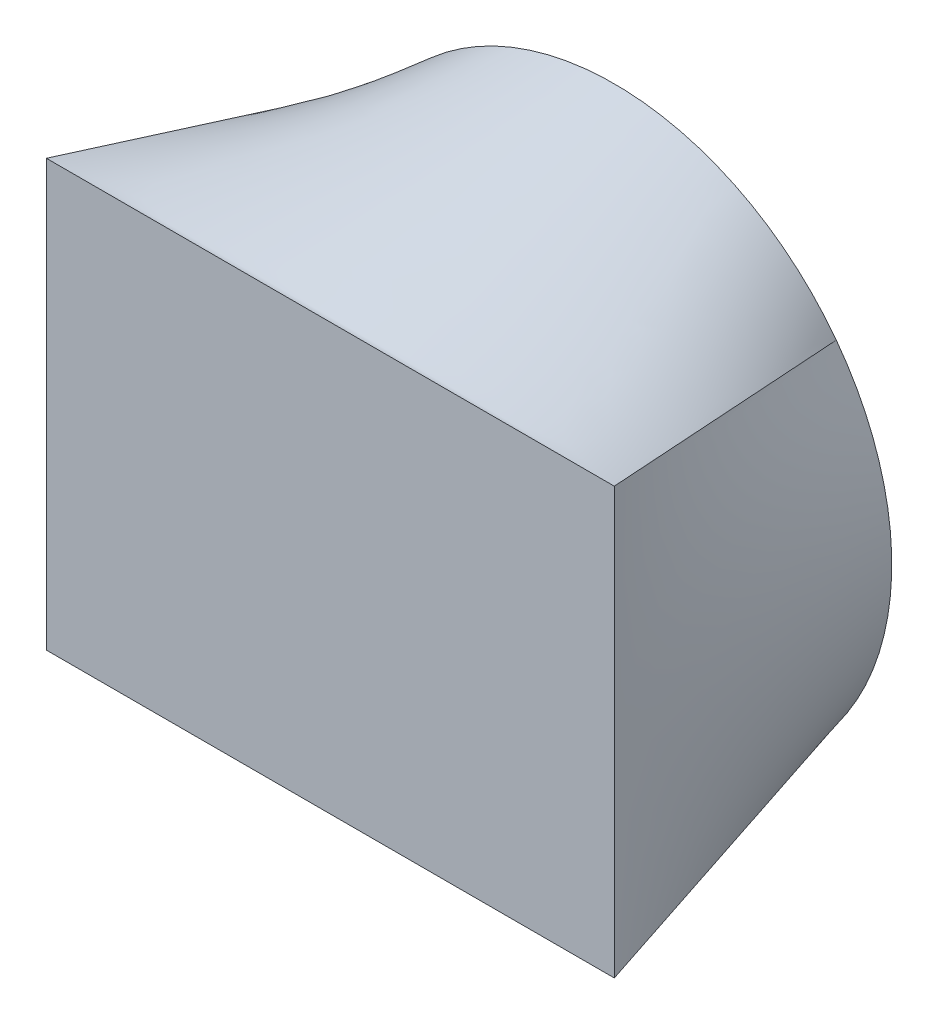
from build123d import *

# Parameters (mm, degrees)
RECHTECK_W = 100
RECHTECK_H = 75


with BuildPart() as part:
    # Rechteck → Ausformung1 section 0
    with BuildSketch(Plane.XY):
        with Locations((50, 37.5)):
            Rectangle(RECHTECK_W, RECHTECK_H)
    # Skizze2 for Ausformung1 → Ausformung1 section 1
    with BuildSketch(Plane.XY.offset(-50)):
        with BuildLine():
            # circular arc as an exact rational Bezier (weights 1, cos(half-angle), 1)
            Bezier((10.911799048, 8.183849286), (50, -43.933751983), (89.088200952, 8.183849286), weights=[1, 0.6, 1])
            Bezier((89.088200952, 8.183849286), (111.075313988, 37.5), (89.088200952, 66.816150714), weights=[1, 0.8, 1])
            Bezier((89.088200952, 66.816150714), (50, 118.933751983), (10.911799048, 66.816150714), weights=[1, 0.6, 1])
            Bezier((10.911799048, 66.816150714), (-11.075313988, 37.5), (10.911799048, 8.183849286), weights=[1, 0.8, 1])
        make_face()
    loft()


solid = part.part
